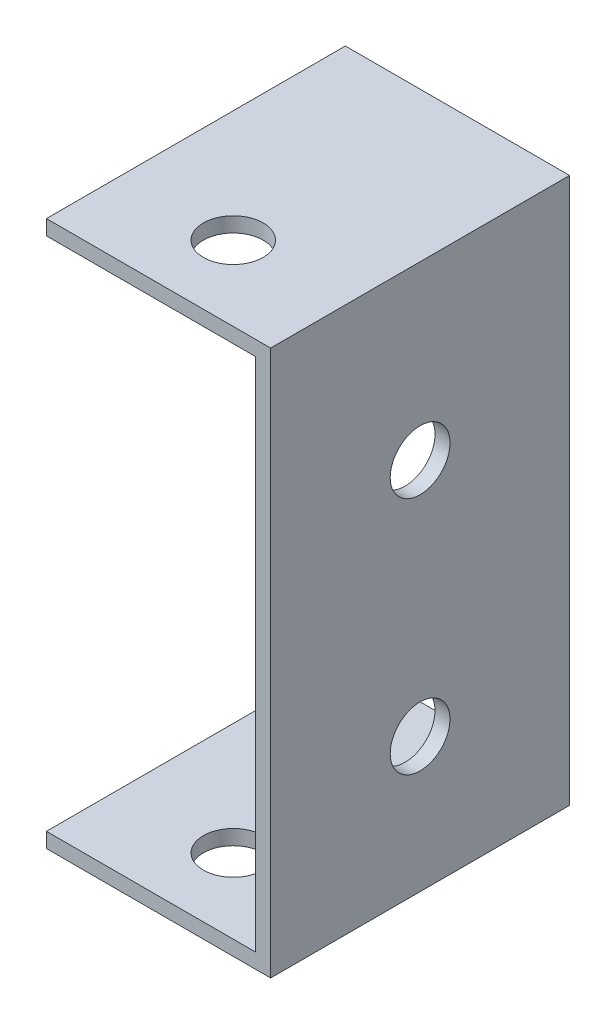
from build123d import *

# Parameters (mm, degrees)
EXTRUDE_1_DEPTH     = 40
SKETCH_3_R          = 4
CUT_EXTRUDE_1_DEPTH = 40
SKETCH_4_R          = 4
CUT_EXTRUDE_2_DEPTH = 96


with BuildPart() as part:
    # 草图1 → 凸台-拉伸1 (new body)
    with BuildSketch(Plane.XY):
        Polygon((-61.165760894, 46.995024588), (-31.165760894, 46.995024588), (-31.165760894, -26.004975412), (-61.165760894, -26.004975412), (-61.165760894, -24.004975412), (-33.165760894, -24.004975412), (-33.165760894, 44.995024588), (-61.165760894, 44.995024588), align=None)
    extrude(amount=EXTRUDE_1_DEPTH)

    # 草图3 → 切除-拉伸1 (cut)
    with BuildSketch(Plane.ZY.offset(33.165760894)):
        with Locations((20, 23.995024588)):
            Circle(SKETCH_3_R)
        with Locations((20, -8.004975412)):
            Circle(SKETCH_3_R)
    extrude(amount=-CUT_EXTRUDE_1_DEPTH, mode=Mode.SUBTRACT)

    # 草图4 → 切除-拉伸2 (cut)
    with BuildSketch(Plane(origin=(0, 46.995024588, 0), x_dir=(1, 0, 0), z_dir=(0, 1, 0))):
        with Locations((-46.165760894, -30)):
            Circle(SKETCH_4_R)
    extrude(amount=-CUT_EXTRUDE_2_DEPTH, mode=Mode.SUBTRACT)


solid = part.part
